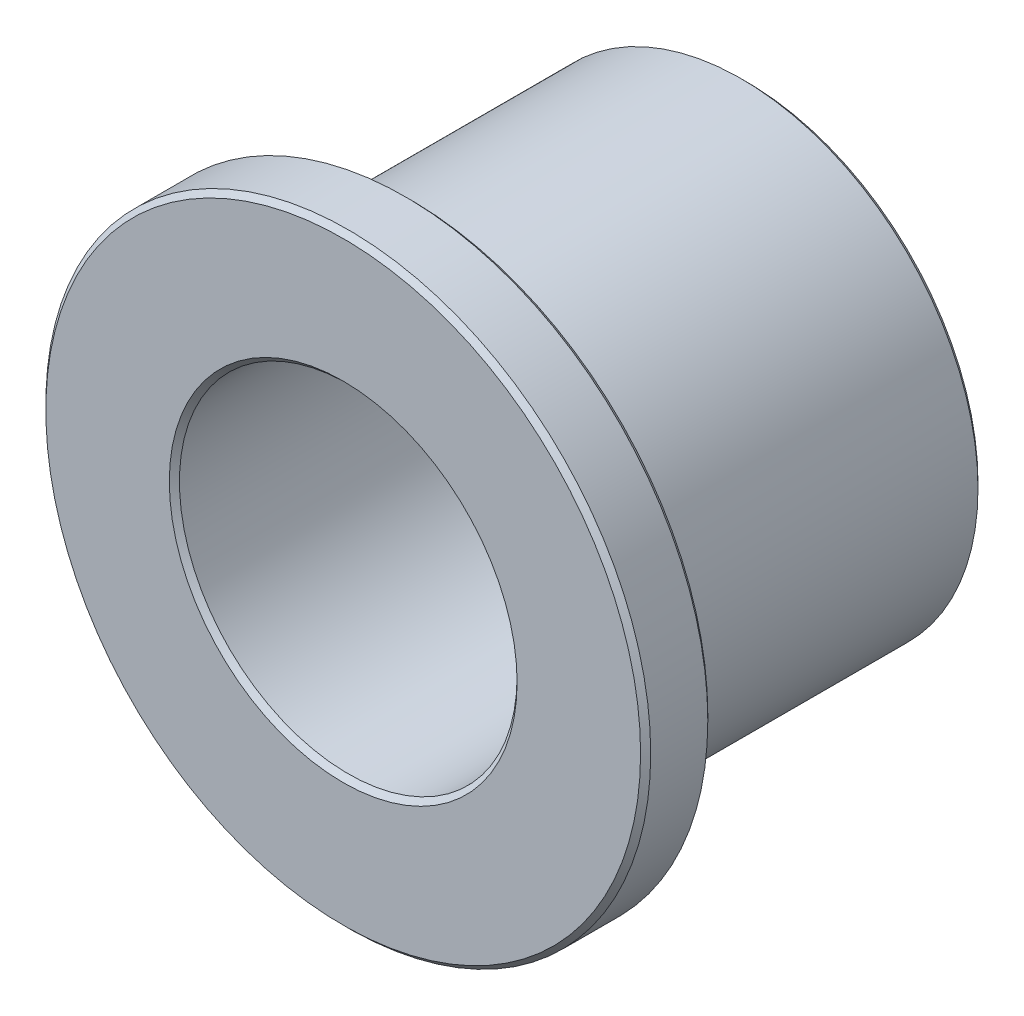
from build123d import *

# Parameters (mm, degrees)
BOSS_EXTRUDE1_START = 4.7625
SKETCH3_R           = 7.14375
SKETCH3_R_2         = 3.9878
BOSS_EXTRUDE1_DEPTH = 1.5875
BOSS_EXTRUDE2_START = 3.175
SKETCH4_R           = 5.588
SKETCH4_R_2         = 3.9878
BOSS_EXTRUDE2_DEPTH = 7.9375
CHAMFER1_SIZE       = 0.119634


with BuildPart() as part:
    # Sketch3 → Boss-Extrude1 (new body)
    with BuildSketch(Plane.XY.offset(BOSS_EXTRUDE1_START)):
        Circle(SKETCH3_R)
        Circle(SKETCH3_R_2, mode=Mode.SUBTRACT)
    extrude(amount=-BOSS_EXTRUDE1_DEPTH)

    # Sketch4 → Boss-Extrude2 (add)
    with BuildSketch(Plane.XY.offset(BOSS_EXTRUDE2_START)):
        Circle(SKETCH4_R)
        Circle(SKETCH4_R_2, mode=Mode.SUBTRACT)
    extrude(amount=-BOSS_EXTRUDE2_DEPTH)

    # Chamfer1
    chamfer1_edges = [part.edges().sort_by_distance(p)[0] for p in [
        (-3.9878, 0, -4.7625),
        (-5.588, 0, 3.175),
        (-7.14375, 0, 4.7625),
        (-7.14375, 0, 3.175),
        (-3.9878, 0, 4.7625),
        (-5.588, 0, -4.7625),
    ]]
    chamfer(chamfer1_edges, length=CHAMFER1_SIZE)


solid = part.part
